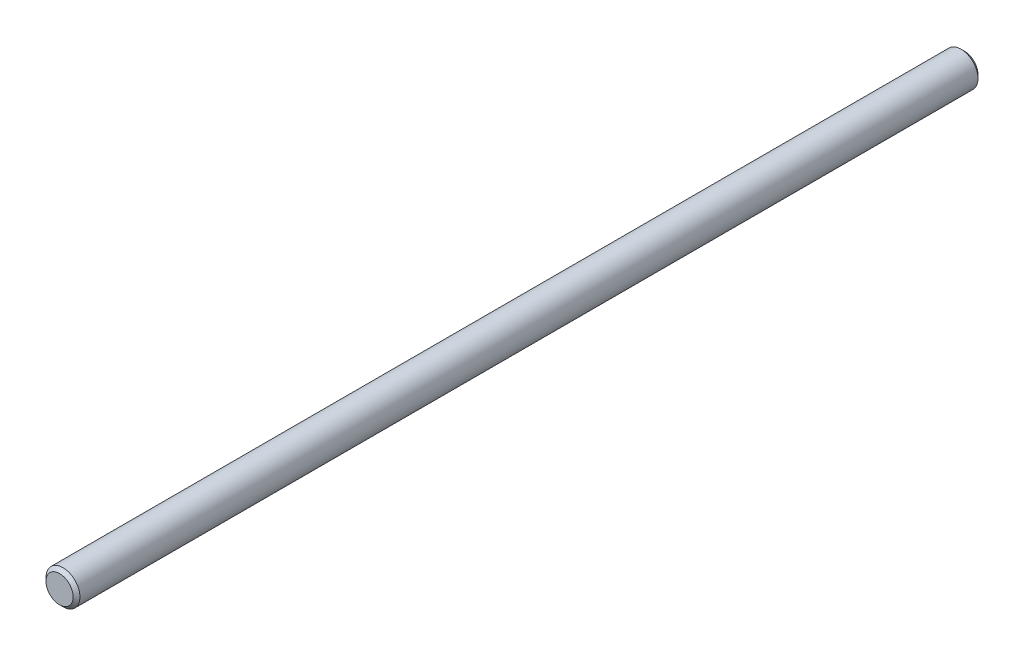
from build123d import *

# Parameters (mm, degrees)
SKETCH1_R      = 4.7625
EXTRUDE1_DEPTH = 127
CHAMFER1_SIZE  = 0.9525


with BuildPart() as part:
    # Sketch1 → Extrude1 (new body, symmetric)
    with BuildSketch(Plane.XY):
        Circle(SKETCH1_R)
    extrude(amount=EXTRUDE1_DEPTH, both=True)

    # Chamfer1
    chamfer1_edges = [part.edges().sort_by_distance(p)[0] for p in [
        (-4.7625, 0, -127),
        (-4.7625, 0, 127),
    ]]
    chamfer(chamfer1_edges, length=CHAMFER1_SIZE)


solid = part.part
